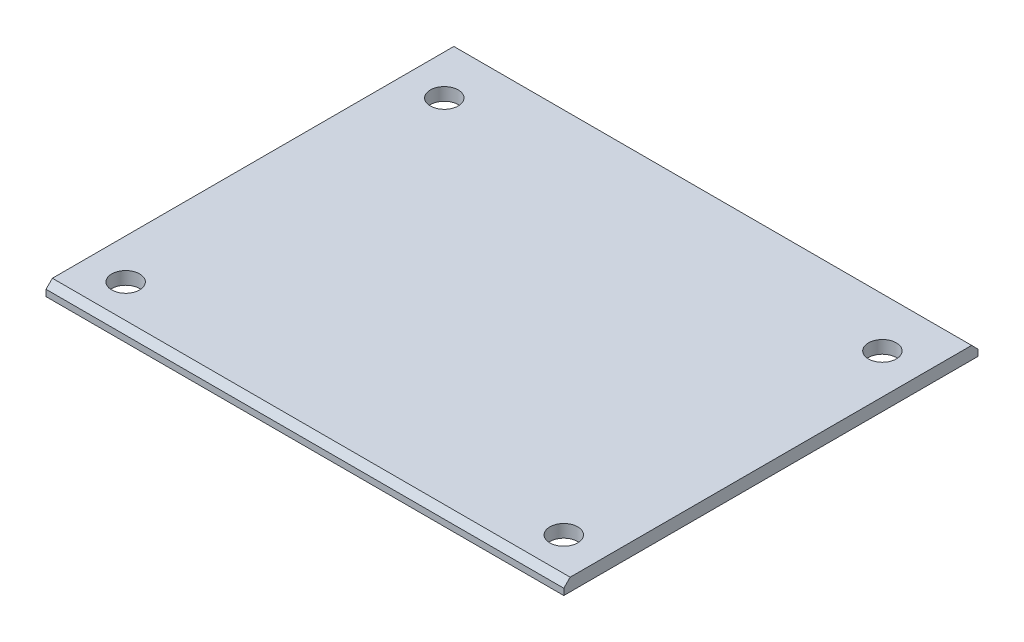
from build123d import *

# Parameters (mm, degrees)
SKETCH1_W           = 65
SKETCH1_H           = 52
BOSS_EXTRUDE1_DEPTH = 1.6
SKETCH2_R           = 1.75
CUT_EXTRUDE1_DEPTH  = 2.6
CHAMFER1_SIZE       = 0.8


with BuildPart() as part:
    # Sketch1 → Boss-Extrude1 (new body)
    with BuildSketch(Plane(origin=(0, 0, 0), x_dir=(1, 0, 0), z_dir=(0, 1, 0))):
        Rectangle(SKETCH1_W, SKETCH1_H)
    extrude(amount=BOSS_EXTRUDE1_DEPTH)

    # Sketch2 → Cut-Extrude1 (cut, through all)
    with BuildSketch(Plane(origin=(0, 1.6, 0), x_dir=(1, 0, 0), z_dir=(0, 1, 0))):
        with Locations((-27.5, -21)):
            Circle(SKETCH2_R)
        with Locations((-27.5, 19)):
            Circle(SKETCH2_R)
        with Locations((27.5, 19)):
            Circle(SKETCH2_R)
        with Locations((27.5, -21)):
            Circle(SKETCH2_R)
    extrude(amount=-CUT_EXTRUDE1_DEPTH, mode=Mode.SUBTRACT)

    # Chamfer1
    chamfer1_edges = [part.edges().sort_by_distance(p)[0] for p in [
        (0, 1.6, 26),
        (0, 1.6, -26),
    ]]
    chamfer(chamfer1_edges, length=CHAMFER1_SIZE)


solid = part.part
